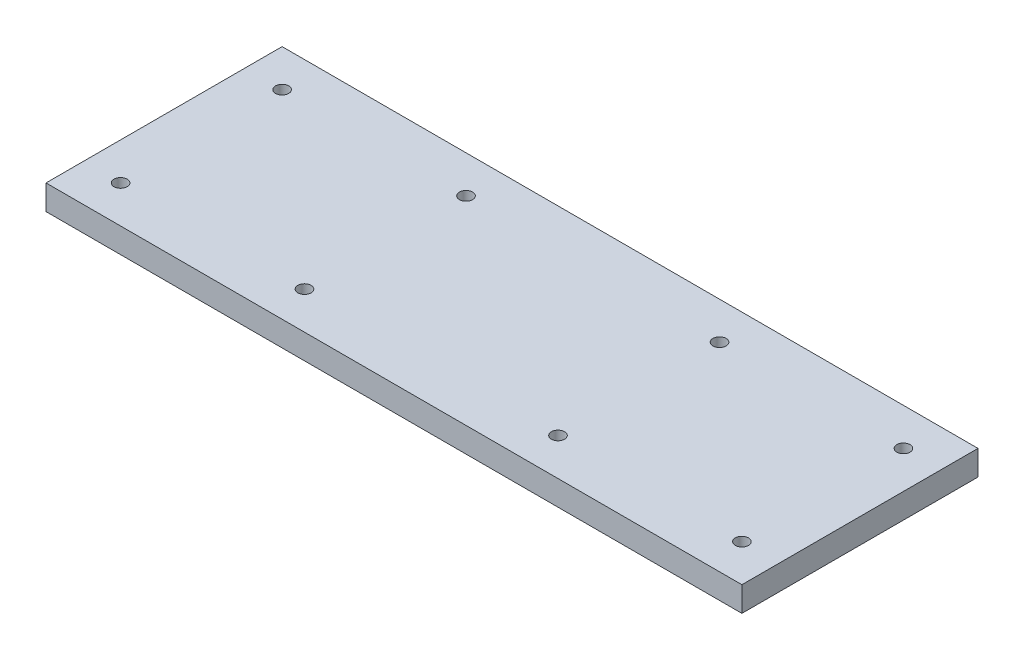
from build123d import *

# Parameters (mm, degrees)
SKETCH1_W            = 280
SKETCH1_H            = 95
BOSS_EXTRUDE1_DEPTH  = 10
M5_CLEARANCE_SLOT1_D = 5.3


with BuildPart() as part:
    # Sketch1 → Boss-Extrude1 (new body)
    with BuildSketch(Plane(origin=(0, 0, 0), x_dir=(1, 0, 0), z_dir=(0, 1, 0))):
        Rectangle(SKETCH1_W, SKETCH1_H)
    extrude(amount=BOSS_EXTRUDE1_DEPTH)

    # M5 Clearance Slot1 (through all)
    with Locations(Plane(origin=(0, 10, 0), x_dir=(1, 0, 0), z_dir=(0, 1, 0))):
        with Locations((-125, -32.5), (-125, 32.5), (-51, 32.5), (-51, -32.5), (125, 32.5), (125, -32.5), (51, -32.5), (51, 32.5)):
            Hole(M5_CLEARANCE_SLOT1_D / 2)


solid = part.part
